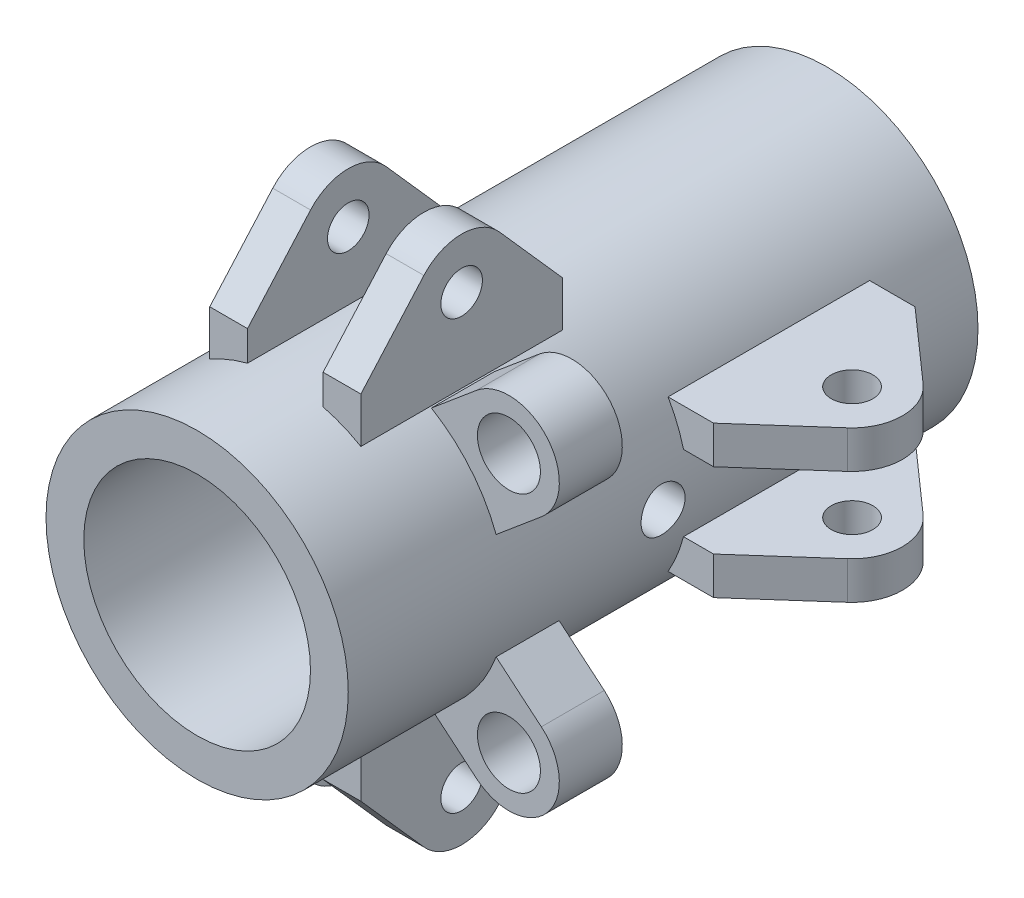
from build123d import *

# Parameters (mm, degrees)
SKETCH_1_R               = 12
SKETCH_1_R_2             = 9
EXTRUDE_1_DEPTH          = 50
SKETCH_2_R               = 1.65
EXTRUDE_2_DEPTH          = 3
SKETCH_3_R               = 1.75
CUT_EXTRUDE_1_DEPTH      = 13
CUT_EXTRUDE_1_DEPTH_BACK = 13
MIRROR_2_COPY_1_SKETCH_R = 1.65
MIRROR_2_COPY_1_DEPTH    = 3
SKETCH_5_R               = 1.65
EXTRUDE_3_DEPTH          = 3
SKETCH_6_R               = 2.5
EXTRUDE_4_DEPTH          = 2.5


with BuildPart() as part:
    # ｽｹｯﾁ1 → ﾎﾞｽ - 押し出し1 (new body)
    with BuildSketch(Plane.XY):
        Circle(SKETCH_1_R)
        Circle(SKETCH_1_R_2, mode=Mode.SUBTRACT)
    extrude(amount=EXTRUDE_1_DEPTH)

    # ｽｹｯﾁ2 → ﾎﾞｽ - 押し出し2 (add)
    with BuildSketch(Plane(origin=(3, 0, 0), x_dir=(0, 0, -1), z_dir=(1, 0, 0))):
        with BuildLine():
            Line((-43, 9), (-43, 14))
            Line((-43, 14), (-37.994493332, 19.651982218))
            ThreePointArc((-37.994493332, 19.651982218), (-35, 21), (-32.005506668, 19.651982218))
            Line((-32.005506668, 19.651982218), (-27, 14))
            Line((-27, 14), (-27, 9))
            Line((-27, 9), (-43, 9))
        make_face()
        with Locations((-35, 17)):
            Circle(SKETCH_2_R, mode=Mode.SUBTRACT)
    extrude_2 = extrude(amount=EXTRUDE_2_DEPTH)

    # ﾐﾗｰ1: ﾎﾞｽ - 押し出し2 across plane
    add(extrude_2.mirror(Plane(origin=(0, 0, 0), x_dir=(0, 0, 1), z_dir=(1, 0, 0))))

    # ｽｹｯﾁ3 → ｶｯﾄ - 押し出し1 (cut, two sides)
    with BuildSketch(Plane(origin=(0, 0, 0), x_dir=(0, 0, -1), z_dir=(1, 0, 0))) as cut_extrude_1_sk:
        with Locations((-25, 0)):
            Circle(SKETCH_3_R)
    extrude(amount=CUT_EXTRUDE_1_DEPTH, mode=Mode.SUBTRACT)
    extrude(cut_extrude_1_sk.sketch, amount=-CUT_EXTRUDE_1_DEPTH_BACK, mode=Mode.SUBTRACT)

    # ﾐﾗｰ2: ﾎﾞｽ - 押し出し2 across plane
    add(extrude_2.mirror(Plane.ZX))

    # ﾐﾗｰ2 copy 1 sketch → ﾐﾗｰ2 copy 1 (add)
    with BuildSketch(Plane(origin=(-3, 0, 0), x_dir=(0, 0, -1), z_dir=(-1, 0, 0))):
        with BuildLine():
            Line((-43, 9), (-43, 14))
            Line((-43, 14), (-37.994493332, 19.651982218))
            ThreePointArc((-37.994493332, 19.651982218), (-35, 21), (-32.005506668, 19.651982218))
            Line((-32.005506668, 19.651982218), (-27, 14))
            Line((-27, 14), (-27, 9))
            Line((-27, 9), (-43, 9))
        make_face()
        with Locations((-35, 17)):
            Circle(MIRROR_2_COPY_1_SKETCH_R, mode=Mode.SUBTRACT)
    extrude(amount=MIRROR_2_COPY_1_DEPTH)

    # ｽｹｯﾁ5 → ﾎﾞｽ - 押し出し3 (add)
    with BuildSketch(Plane(origin=(0, 3, 0), x_dir=(1, 0, 0), z_dir=(0, 1, 0))):
        with BuildLine():
            Line((9, -7), (14, -7))
            Line((14, -7), (19.651982218, -12.005506668))
            ThreePointArc((19.651982218, -12.005506668), (21, -15), (19.651982218, -17.994493332))
            Line((19.651982218, -17.994493332), (14, -23))
            Line((14, -23), (9, -23))
            Line((9, -23), (9, -7))
        make_face()
        with Locations((17, -15)):
            Circle(SKETCH_5_R, mode=Mode.SUBTRACT)
    extrude_3 = extrude(amount=EXTRUDE_3_DEPTH)

    # ﾐﾗｰ3: ﾎﾞｽ - 押し出し3 across plane
    add(extrude_3.mirror(Plane.ZX))

    # ｽｹｯﾁ6 → ﾎﾞｽ - 押し出し4 (add, symmetric)
    with BuildSketch(Plane(origin=(0, 0, 35), x_dir=(-1, 0, 0), z_dir=(0, 0, -1))):
        with BuildLine():
            Line((-6.095653088, 10.336489415), (-9.685560651, 13.348779527))
            ThreePointArc((-9.685560651, 13.348779527), (-15.320888862, 12.855752194), (-14.827861529, 7.220423983))
            Line((-14.827861529, 7.220423983), (-11.237953965, 4.20813387))
            Line((-11.237953965, 4.20813387), (-6.095653088, 10.336489415))
        make_face()
        with Locations((-12.25671109, 10.284601755)):
            Circle(SKETCH_6_R, mode=Mode.SUBTRACT)
    extrude_4 = extrude(amount=EXTRUDE_4_DEPTH, both=True)

    # ﾐﾗｰ4: ﾎﾞｽ - 押し出し4 across plane
    add(extrude_4.mirror(Plane.ZX))


solid = part.part
